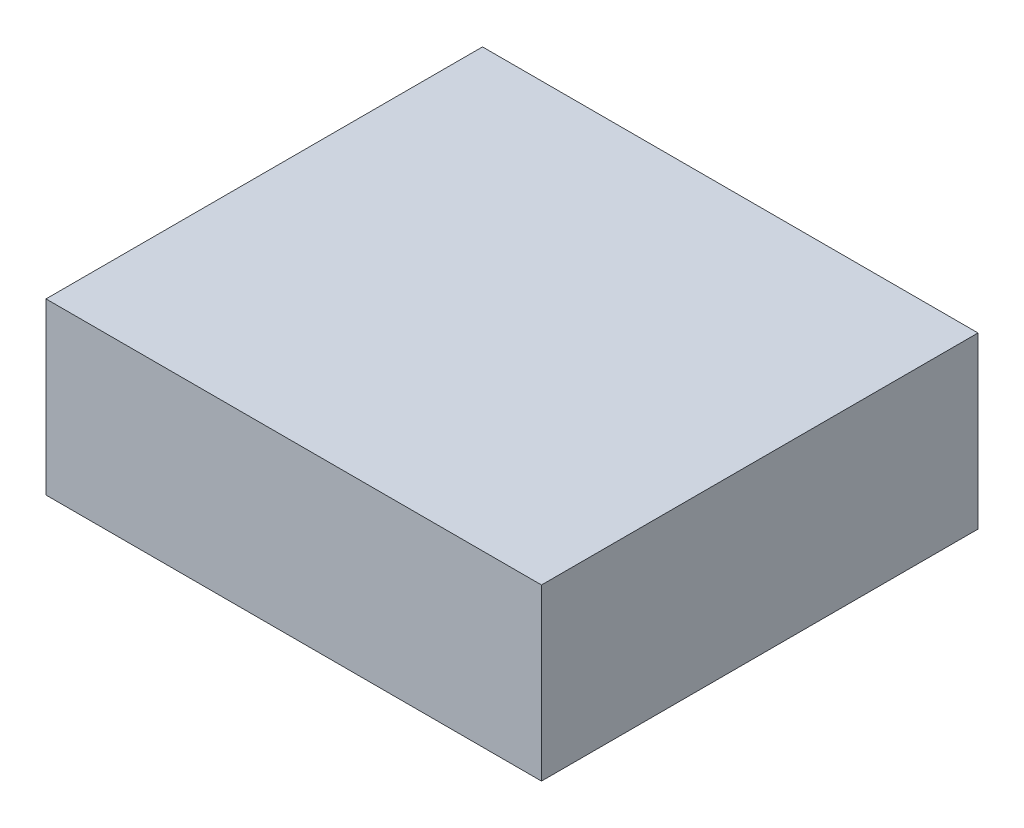
from build123d import *

# Parameters (mm, degrees)
SKETCH1_W           = 105
SKETCH1_H           = 36
BOSS_EXTRUDE1_DEPTH = 92.5


with BuildPart() as part:
    # Sketch1 → Boss-Extrude1 (new body)
    with BuildSketch(Plane.XY):
        with Locations((52.5, 18)):
            Rectangle(SKETCH1_W, SKETCH1_H)
    extrude(amount=BOSS_EXTRUDE1_DEPTH)


solid = part.part
